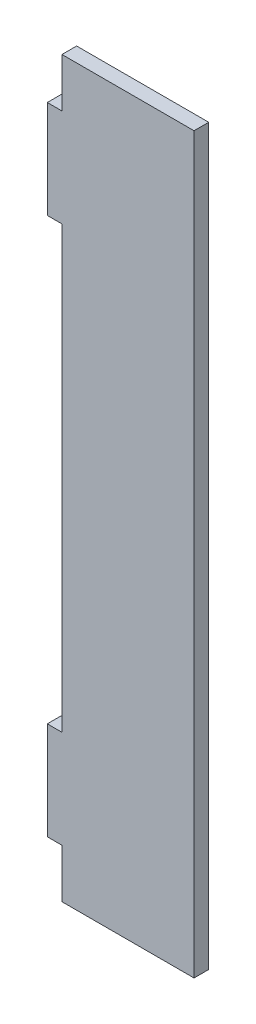
from build123d import *

# Parameters (mm, degrees)
SKETCH1_W           = 30
SKETCH1_H           = 150
BOSS_EXTRUDE1_DEPTH = 3
SKETCH2_W           = 3
SKETCH2_H           = 10
SKETCH2_H_2         = 90
CUT_EXTRUDE1_DEPTH  = 3


with BuildPart() as part:
    # Sketch1 → Boss-Extrude1 (new body)
    with BuildSketch(Plane.XY):
        Rectangle(SKETCH1_W, SKETCH1_H)
    extrude(amount=BOSS_EXTRUDE1_DEPTH)

    # Sketch2 → Cut-Extrude1 (cut)
    with BuildSketch(Plane.XY.offset(3)):
        with Locations((-13.5, 70)):
            Rectangle(SKETCH2_W, SKETCH2_H)
        with Locations((-13.5, -70)):
            Rectangle(SKETCH2_W, SKETCH2_H)
        with Locations((-13.5, 0)):
            Rectangle(SKETCH2_W, SKETCH2_H_2)
    extrude(amount=-CUT_EXTRUDE1_DEPTH, mode=Mode.SUBTRACT)


solid = part.part
